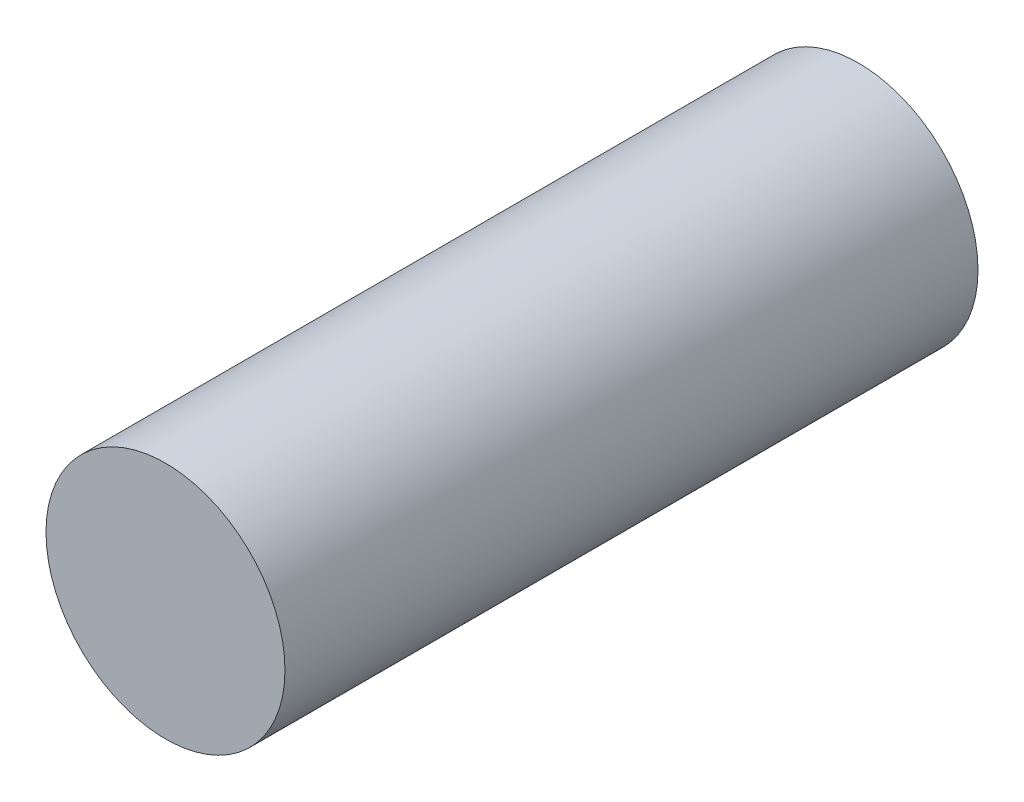
from build123d import *

# Parameters (mm, degrees)
SKETCH_1_R      = 2.5
EXTRUDE_1_DEPTH = 14.5


with BuildPart() as part:
    # 草图1 → 凸台-拉伸1 (new body)
    with BuildSketch(Plane.XY):
        Circle(SKETCH_1_R)
    extrude(amount=EXTRUDE_1_DEPTH)


solid = part.part
